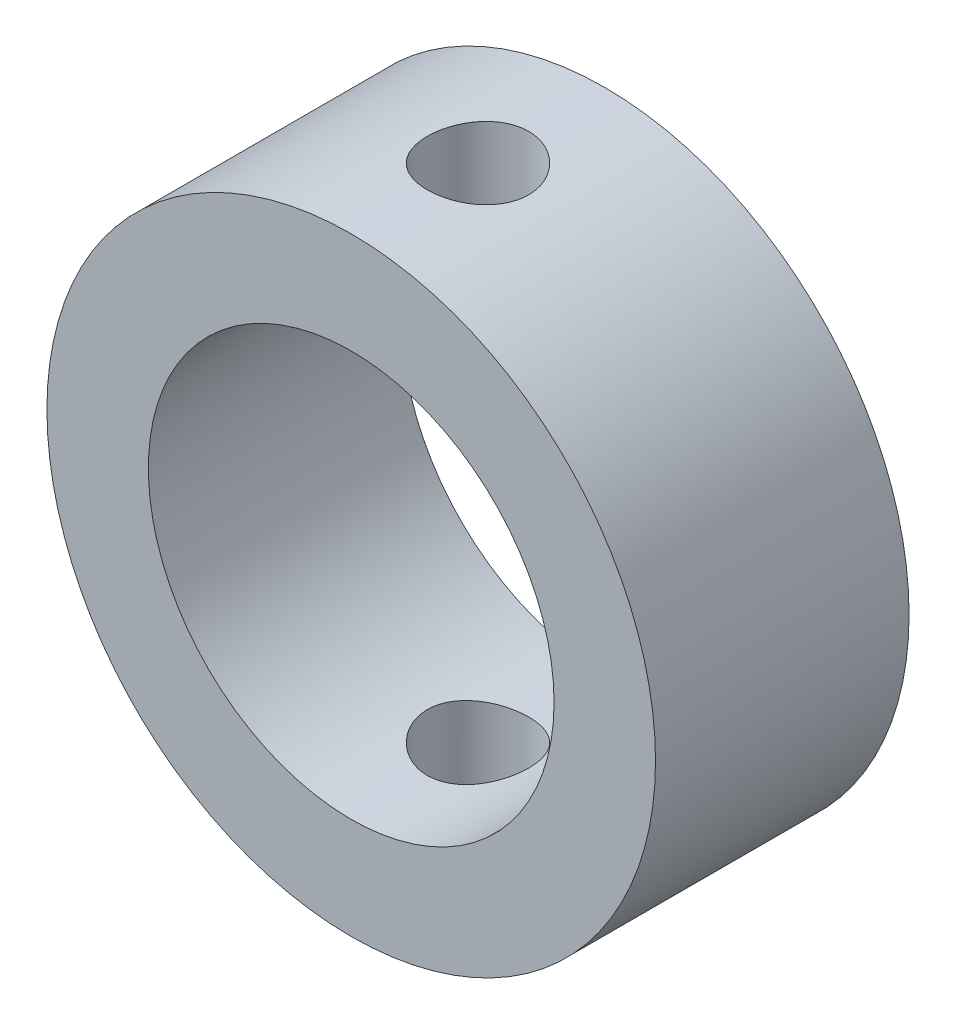
from build123d import *

# Parameters (mm, degrees)
ESQUISSE1_R                  = 9
ESQUISSE1_R_2                = 6
BOSS_EXTRU_1_DEPTH           = 7.5
ENL_V_MAT_EXTRU_1_DEPTH      = 10
ENL_V_MAT_EXTRU_1_DEPTH_BACK = 10
ESQUISSE2_R                  = 1.5


with BuildPart() as part:
    # Esquisse1 → Boss.-Extru.1 (new body)
    with BuildSketch(Plane.XY):
        Circle(ESQUISSE1_R)
        Circle(ESQUISSE1_R_2, mode=Mode.SUBTRACT)
    extrude(amount=BOSS_EXTRU_1_DEPTH)

    # Esquisse2 → Enlèv. mat.-Extru.1 (cut, two sides: drawn at the far end of the back side and taken through both)
    with BuildSketch(Plane(origin=(0, 0, 0), x_dir=(1, 0, 0), z_dir=(0, 1, 0)).offset(-ENL_V_MAT_EXTRU_1_DEPTH_BACK)):
        with Locations((0, -3.75)):
            Circle(ESQUISSE2_R)
    extrude(amount=ENL_V_MAT_EXTRU_1_DEPTH + ENL_V_MAT_EXTRU_1_DEPTH_BACK, mode=Mode.SUBTRACT)


solid = part.part
